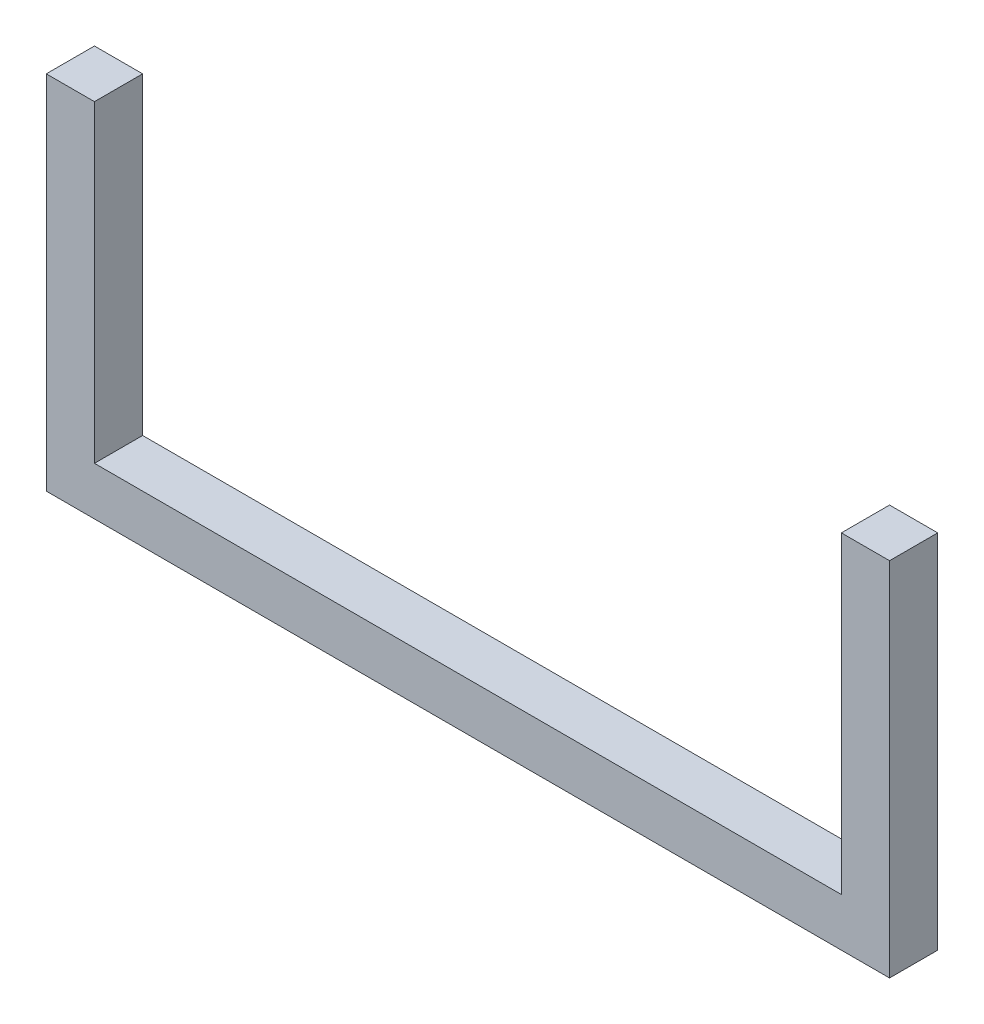
from build123d import *

# Parameters (mm, degrees)
EXTRUDE_1_DEPTH = 20


with BuildPart() as part:
    # 스케치2 → 보스-돌출1 (new body)
    with BuildSketch(Plane.XY):
        Polygon((0, 0), (-350, 0), (-350, 150), (-330, 150), (-330, 20), (-20, 20), (-20, 150), (0, 150), align=None)
    extrude(amount=EXTRUDE_1_DEPTH)


solid = part.part
